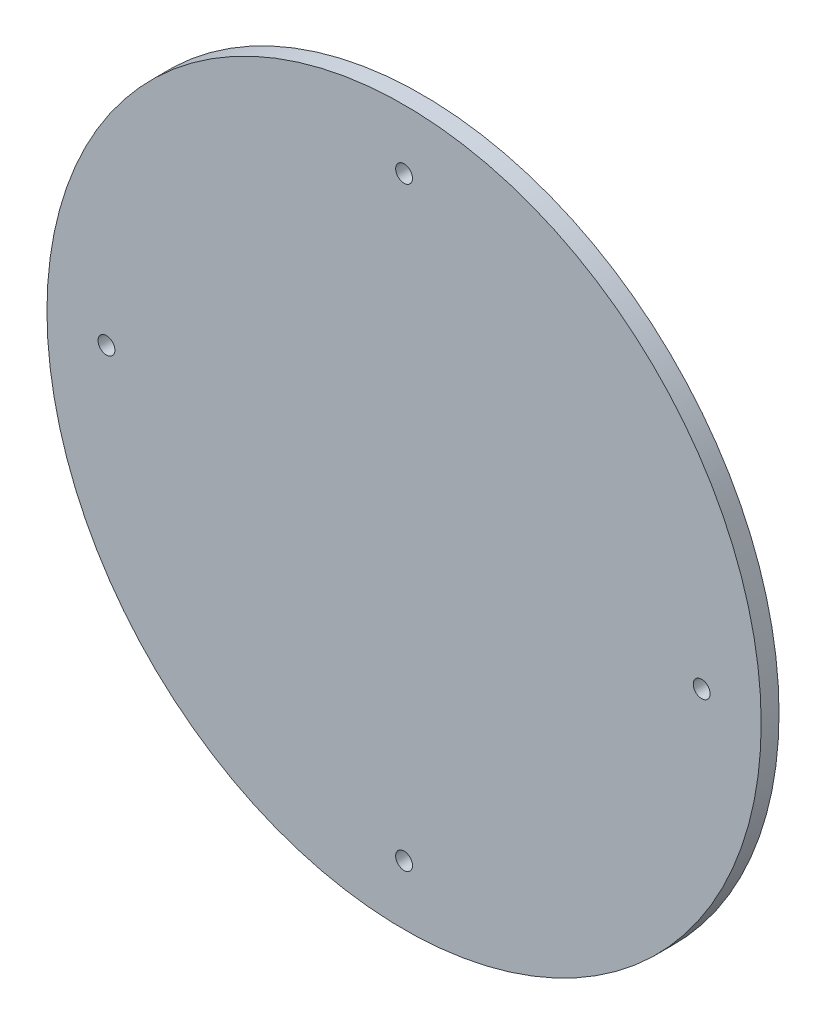
from build123d import *

# Parameters (mm, degrees)
SKETCH1_R                  = 95.25
BOSS_EXTRUDE1_DEPTH        = 4.7625
F_12_24_TAPPED_HOLE1_D     = 4.4958
F_12_24_TAPPED_HOLE1_DEPTH = 14.224


with BuildPart() as part:
    # Sketch1 → Boss-Extrude1 (new body)
    with BuildSketch(Plane.XY):
        Circle(SKETCH1_R)
    extrude(amount=BOSS_EXTRUDE1_DEPTH)

    # #12-24 Tapped Hole1
    with Locations(Plane.XY.offset(4.7625)):
        with Locations((0, 79.375), (-79.375, 0), (79.375, 0), (0, -79.375)):
            Hole(F_12_24_TAPPED_HOLE1_D / 2, depth=F_12_24_TAPPED_HOLE1_DEPTH)


solid = part.part
